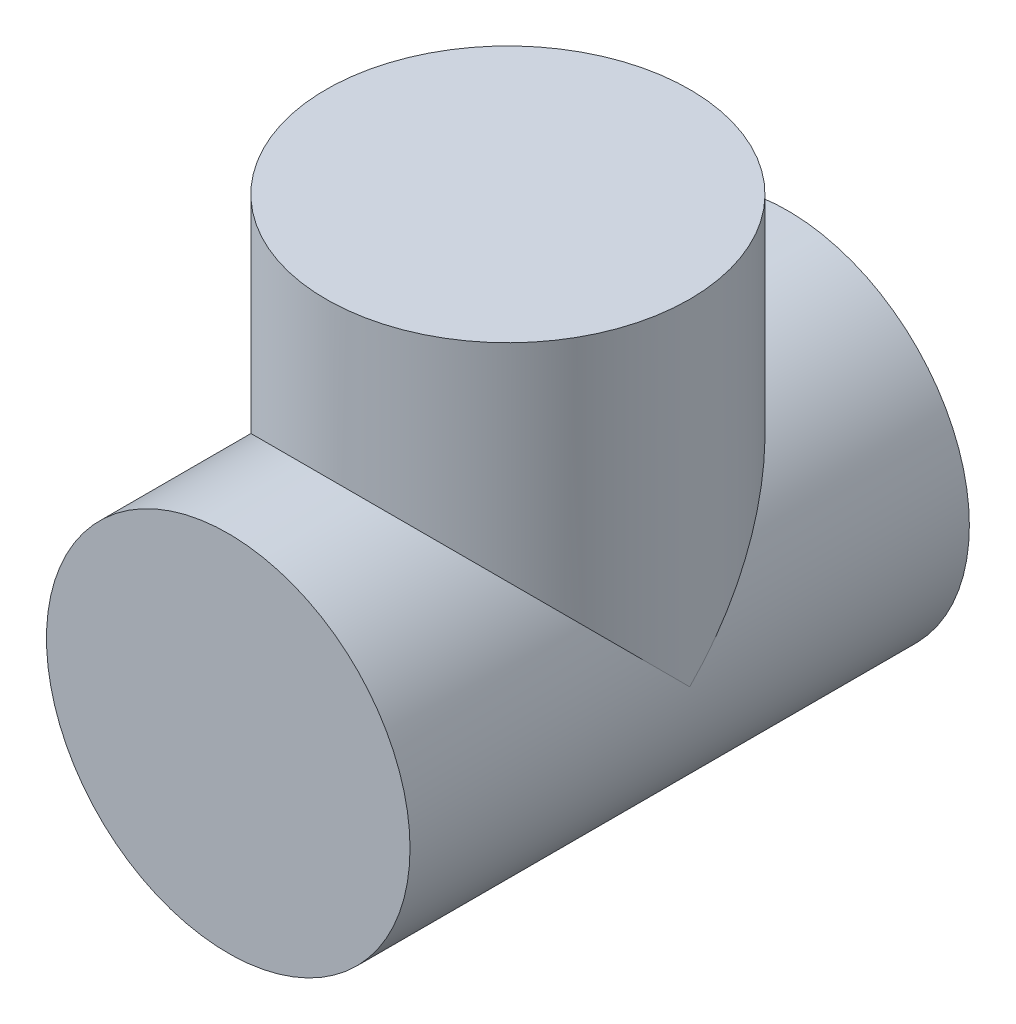
from build123d import *

# Parameters (mm, degrees)
SKETCH2_R = 65


with BuildPart() as part:
    # Sweep1: sweep along a path in Sketch1
    with BuildLine(Plane(origin=(0, 0, 0), x_dir=(0, 0, -1), z_dir=(1, 0, 0))) as sweep1_path:
        Line((-50, 0), (50, 0))
        Line((50, 0), (50, 120))
    # Sketch2 → Sweep1 (sweep)
    with BuildSketch(Plane.XY.offset(50)):
        Circle(SKETCH2_R)
    sweep1 = sweep(path=sweep1_path.line, transition=Transition.RIGHT)

    # Mirror1: Sweep1 across plane
    add(sweep1.mirror(Plane.XY.offset(-50)))


solid = part.part
